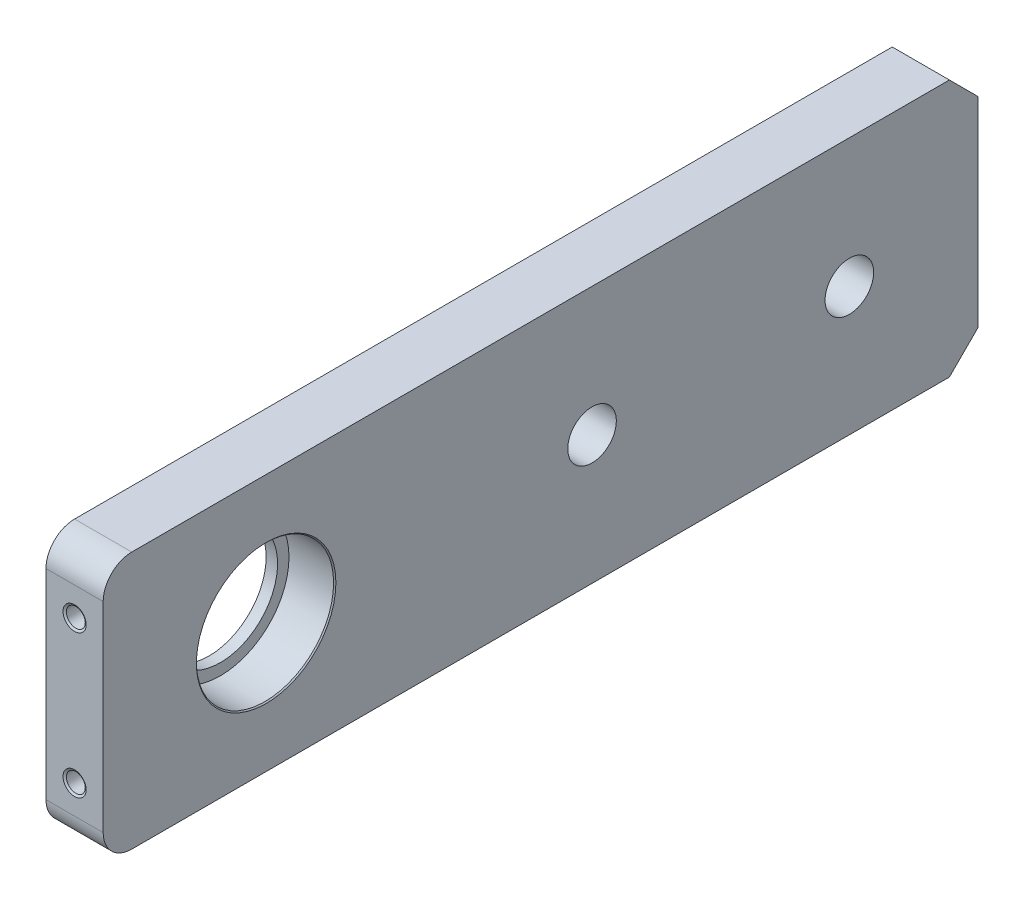
from build123d import *

# Parameters (mm, degrees)
SKETCH_1_W                   = 153
SKETCH_1_H                   = 45
SKETCH_1_R                   = 10
SKETCH_1_R_2                 = 4.25
EXTRUDE_1_DEPTH              = 5
SKETCH_6_R                   = 12
CUT_EXTRUDE_1028_DEPTH       = 8
CHAMFER_1_SIZE               = 5
FILLET_1_R                   = 5
CHAMFER_2_SIZE               = 0.2
HOLE_WIZARD_M4_1_D           = 3.3
HOLE_WIZARD_M4_1_DEPTH       = 15.5
HOLE_WIZARD_M4_1_CSINK_D     = 4.05
HOLE_WIZARD_M4_1_CSINK_ANGLE = 120


with BuildPart() as part:
    # 草图1 → 凸台-拉伸1 (new body, symmetric)
    with BuildSketch(Plane(origin=(0, 0, 0), x_dir=(0, 0, -1), z_dir=(1, 0, 0))):
        with Locations((76.5, -22.5)):
            Rectangle(SKETCH_1_W, SKETCH_1_H)
        with Locations((28.5, -22.5)):
            Circle(SKETCH_1_R, mode=Mode.SUBTRACT)
        with Locations((85.5, -22.5)):
            Circle(SKETCH_1_R_2, mode=Mode.SUBTRACT)
        with Locations((130.5, -22.5)):
            Circle(SKETCH_1_R_2, mode=Mode.SUBTRACT)
    extrude(amount=EXTRUDE_1_DEPTH, both=True)

    # 草图6 → Cut-Extrude 1028 (cut)
    with BuildSketch(Plane.ZY.offset(-5)):
        with Locations((-28.5, -22.5)):
            Circle(SKETCH_6_R)
    extrude(amount=CUT_EXTRUDE_1028_DEPTH, mode=Mode.SUBTRACT)

    # 倒角1
    chamfer_1_edges = [part.edges().sort_by_distance(p)[0] for p in [
        (0, 0, -153),
        (0, -45, -153),
    ]]
    chamfer(chamfer_1_edges, length=CHAMFER_1_SIZE)

    # 圆角1
    fillet_1_edges = [part.edges().sort_by_distance(p)[0] for p in [
        (0, 0, 0),
        (0, -45, 0),
    ]]
    fillet(fillet_1_edges, radius=FILLET_1_R)

    # 倒角2
    chamfer_2_edges = [part.edges().sort_by_distance(p)[0] for p in [
        (5, -22.5, -40.5),
    ]]
    chamfer(chamfer_2_edges, length=CHAMFER_2_SIZE)

    # M4 螺纹孔1
    with Locations(Plane.XY):
        with Locations((0, -10), (0, -35)):
            CounterSinkHole(HOLE_WIZARD_M4_1_D / 2, HOLE_WIZARD_M4_1_CSINK_D / 2, depth=HOLE_WIZARD_M4_1_DEPTH, counter_sink_angle=HOLE_WIZARD_M4_1_CSINK_ANGLE)


solid = part.part
